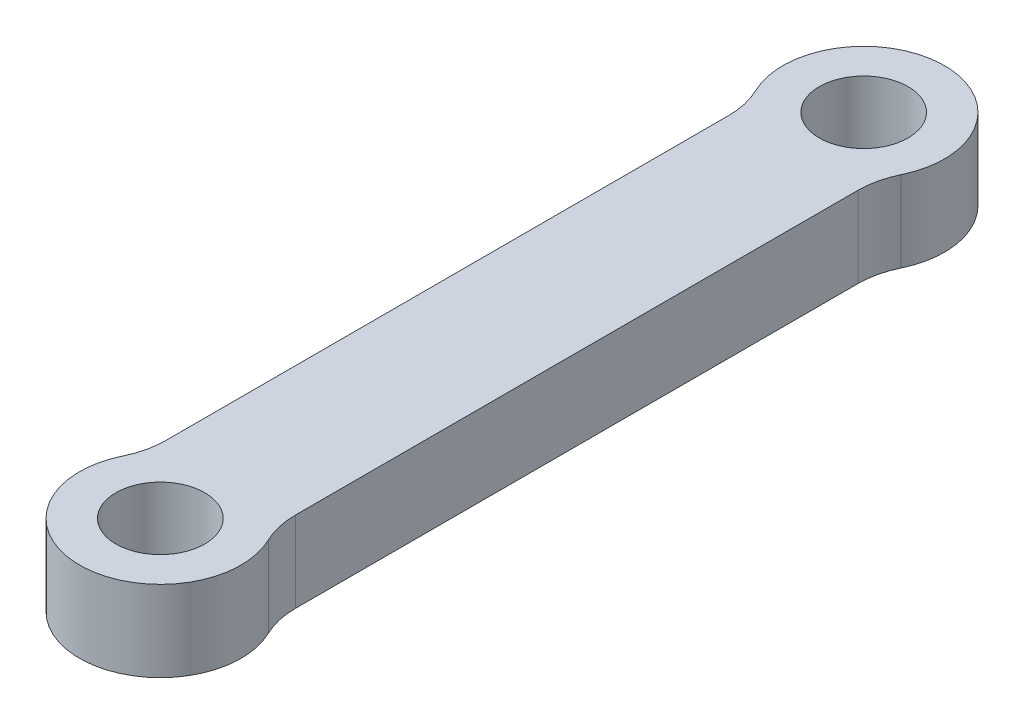
from build123d import *

# Parameters (mm, degrees)
BOSS_EXTRUDE1_DEPTH = 5
SKETCH2_R           = 2.75
CUT_EXTRUDE2_DEPTH  = 6
SKETCH3_R           = 5
SKETCH3_R_2         = 2.75
BOSS_EXTRUDE2_DEPTH = 5
FILLET1_R           = 5


with BuildPart() as part:
    # Sketch1 → Boss-Extrude1 (new body)
    with BuildSketch(Plane(origin=(0, 0, 0), x_dir=(1, 0, 0), z_dir=(0, 1, 0))):
        with BuildLine():
            Line((-4, -21.75), (-4, 21.75))
            ThreePointArc((-4, 21.75), (0, 25.75), (4, 21.75))
            Line((4, 21.75), (4, -21.75))
            ThreePointArc((4, -21.75), (0, -25.75), (-4, -21.75))
        make_face()
    extrude(amount=BOSS_EXTRUDE1_DEPTH)

    # Sketch2 → Cut-Extrude2 (cut, through all)
    with BuildSketch(Plane(origin=(0, 5, 0), x_dir=(1, 0, 0), z_dir=(0, 1, 0))):
        with Locations((0, 21.75)):
            Circle(SKETCH2_R)
        with Locations((0, -21.75)):
            Circle(SKETCH2_R)
    extrude(amount=-CUT_EXTRUDE2_DEPTH, mode=Mode.SUBTRACT)

    # Sketch3 → Boss-Extrude2 (add)
    with BuildSketch(Plane(origin=(0, 5, 0), x_dir=(1, 0, 0), z_dir=(0, 1, 0))):
        with Locations((0, 21.75)):
            Circle(SKETCH3_R)
        with Locations((0, 21.75)):
            Circle(SKETCH3_R_2, mode=Mode.SUBTRACT)
        with Locations((0, -21.75)):
            Circle(SKETCH3_R)
        with Locations((0, -21.75)):
            Circle(SKETCH3_R_2, mode=Mode.SUBTRACT)
    extrude(amount=-BOSS_EXTRUDE2_DEPTH)

    # Fillet1
    fillet1_edges = [part.edges().sort_by_distance(p)[0] for p in [
        (-4, 2.5, -18.75),
        (4, 2.5, -18.75),
        (-4, 2.5, 18.75),
        (4, 2.5, 18.75),
    ]]
    fillet(fillet1_edges, radius=FILLET1_R)


solid = part.part
